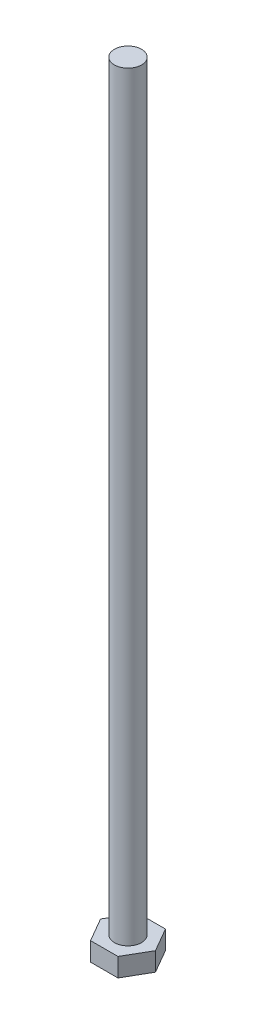
from build123d import *

# Parameters (mm, degrees)
BOSS_EXTRUDE1_DEPTH = 4.365625
SKETCH2_R           = 3.175
BOSS_EXTRUDE2_DEPTH = 177.8


with BuildPart() as part:
    # Sketch1 → Boss-Extrude1 (new body)
    with BuildSketch(Plane(origin=(0, 0, 0), x_dir=(1, 0, 0), z_dir=(0, 1, 0))):
        Polygon((6.415804866, 0), (3.207902433, 5.55625), (-3.207902433, 5.55625), (-6.415804866, 0), (-3.207902433, -5.55625), (3.207902433, -5.55625), align=None)
    extrude(amount=BOSS_EXTRUDE1_DEPTH)

    # Sketch2 → Boss-Extrude2 (add)
    with BuildSketch(Plane(origin=(0, 4.365625, 0), x_dir=(1, 0, 0), z_dir=(0, 1, 0))):
        Circle(SKETCH2_R)
    extrude(amount=BOSS_EXTRUDE2_DEPTH)


solid = part.part
